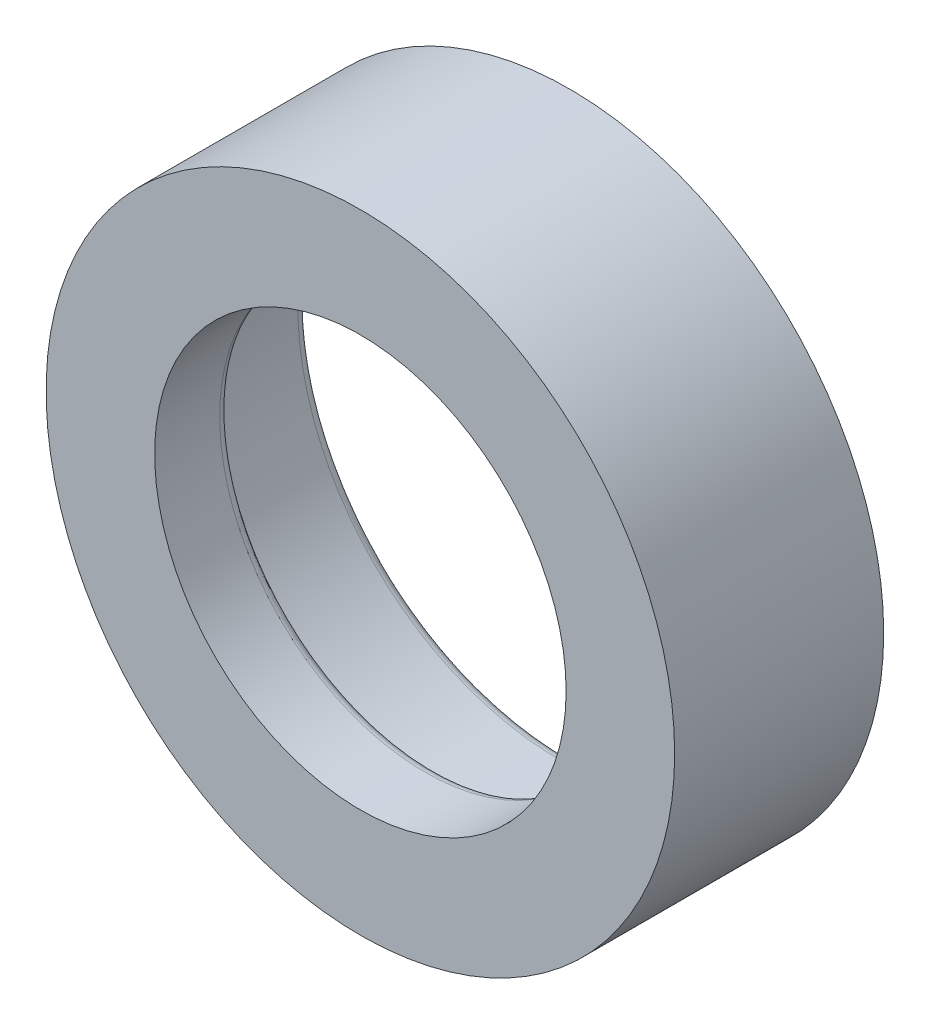
from build123d import *

# Parameters (mm, degrees)
SKETCH1_R           = 30.55
BOSS_EXTRUDE1_DEPTH = 20.32
SKETCH2_R           = 25.404
CUT_EXTRUDE1_DEPTH  = 13
SKETCH3_R           = 20
CUT_EXTRUDE2_DEPTH  = 21.32
FILLET1_R           = 1
FILLET2_R           = 1


with BuildPart() as part:
    # Sketch1 → Boss-Extrude1 (new body)
    with BuildSketch(Plane.XY):
        Circle(SKETCH1_R)
    extrude(amount=BOSS_EXTRUDE1_DEPTH)

    # Sketch2 → Cut-Extrude1 (cut)
    with BuildSketch(Plane(origin=(0, 0, 0), x_dir=(1, 0, 0), z_dir=(0, 0, -1))):
        Circle(SKETCH2_R)
    extrude(amount=-CUT_EXTRUDE1_DEPTH, mode=Mode.SUBTRACT)

    # Sketch3 → Cut-Extrude2 (cut, through all)
    with BuildSketch(Plane.XY.offset(20.32)):
        Circle(SKETCH3_R)
    extrude(amount=-CUT_EXTRUDE2_DEPTH, mode=Mode.SUBTRACT)

    # Fillet1
    fillet1_edges = [part.edges().sort_by_distance(p)[0] for p in [
        (-25.404, 0, 0),
    ]]
    fillet(fillet1_edges, radius=FILLET1_R)

    # Fillet2
    fillet2_edges = [part.edges().sort_by_distance(p)[0] for p in [
        (-20, 0, 13),
    ]]
    fillet(fillet2_edges, radius=FILLET2_R)


solid = part.part
